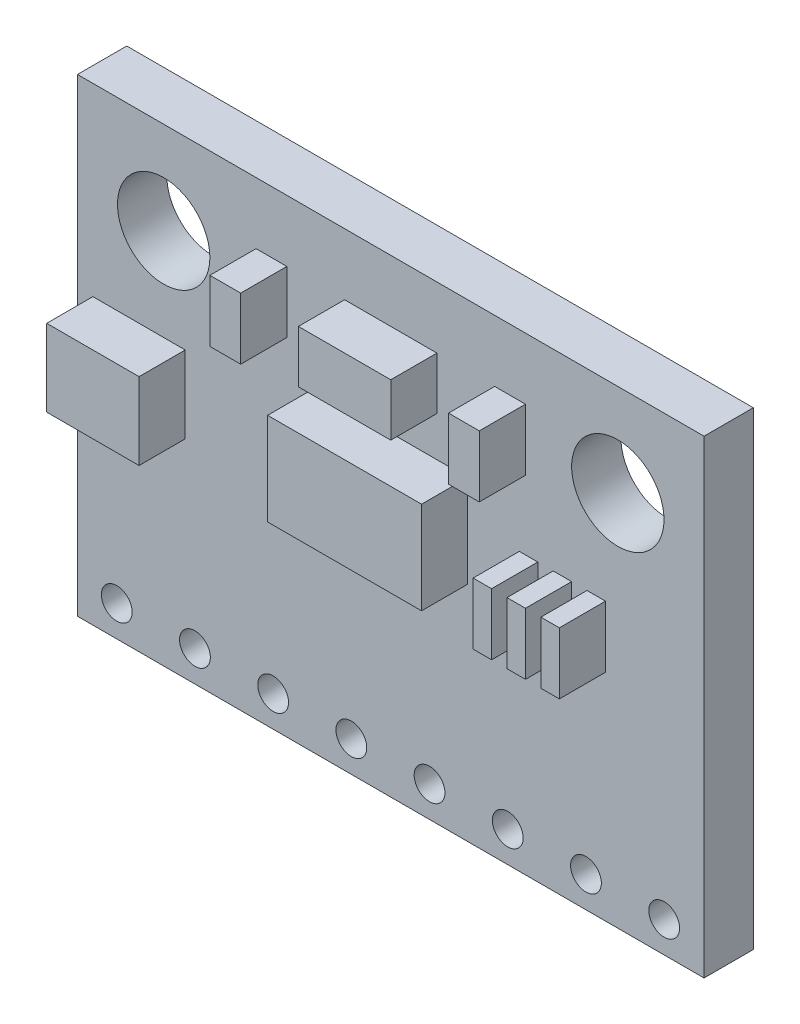
from build123d import *

# Parameters (mm, degrees)
SKETCH1_W           = 20.35
SKETCH1_H           = 15.24
SKETCH1_R           = 1.5
BOSS_EXTRUDE1_DEPTH = 1.6
SKETCH2_W           = 5
SKETCH2_H           = 3
SKETCH2_W_2         = 3
SKETCH2_H_2         = 2.5
SKETCH2_H_3         = 1.7
SKETCH2_W_3         = 1
SKETCH2_H_4         = 2
SKETCH2_W_4         = 0.6
BOSS_EXTRUDE2_DEPTH = 1.5
SKETCH3_R           = 0.5
CUT_EXTRUDE1_DEPTH  = 2.6
LPATTERN1_COUNT     = 5
LPATTERN1_PITCH     = 2.54
LPATTERN1_COL_COUNT = 4
LPATTERN1_COL_PITCH = 2.54


with BuildPart() as part:
    # Sketch1 → Boss-Extrude1 (new body)
    with BuildSketch(Plane.XY):
        Rectangle(SKETCH1_W, SKETCH1_H)
        with Locations((-7.375, 4.62)):
            Circle(SKETCH1_R, mode=Mode.SUBTRACT)
        with Locations((7.375, 4.62)):
            Circle(SKETCH1_R, mode=Mode.SUBTRACT)
    extrude(amount=BOSS_EXTRUDE1_DEPTH)

    # Sketch2 → Boss-Extrude2 (add)
    with BuildSketch(Plane.XY.offset(1.6)):
        with Locations((0, 1.12)):
            Rectangle(SKETCH2_W, SKETCH2_H)
        with Locations((-8.175, 0.37)):
            Rectangle(SKETCH2_W_2, SKETCH2_H_2)
        with Locations((0, 4.77)):
            Rectangle(SKETCH2_W_2, SKETCH2_H_3)
        with Locations((3.875, 4.62)):
            Rectangle(SKETCH2_W_3, SKETCH2_H_4)
        with Locations((-3.875, 4.62)):
            Rectangle(SKETCH2_W_3, SKETCH2_H_4)
        with Locations((4.475, 0.38)):
            Rectangle(SKETCH2_W_4, SKETCH2_H_4)
        with Locations((5.575, 0.38)):
            Rectangle(SKETCH2_W_4, SKETCH2_H_4)
        with Locations((6.675, 0.38)):
            Rectangle(SKETCH2_W_4, SKETCH2_H_4)
    extrude(amount=BOSS_EXTRUDE2_DEPTH)

    # Sketch3 → Cut-Extrude1 (cut, through all)
    with BuildSketch(Plane.XY.offset(1.6)):
        with Locations((-1.28, -6.62)):
            Circle(SKETCH3_R)
    cut_extrude1 = extrude(amount=-CUT_EXTRUDE1_DEPTH, mode=Mode.SUBTRACT)

    # LPattern1: Cut-Extrude1 ×5
    with Locations(*[(i * LPATTERN1_PITCH, 0, 0) for i in range(1, LPATTERN1_COUNT)]):
        add(cut_extrude1, mode=Mode.SUBTRACT)

    # LPattern1 col: Cut-Extrude1 ×4
    with Locations(*[(-i * LPATTERN1_COL_PITCH, 0, 0) for i in range(1, LPATTERN1_COL_COUNT)]):
        add(cut_extrude1, mode=Mode.SUBTRACT)


solid = part.part
